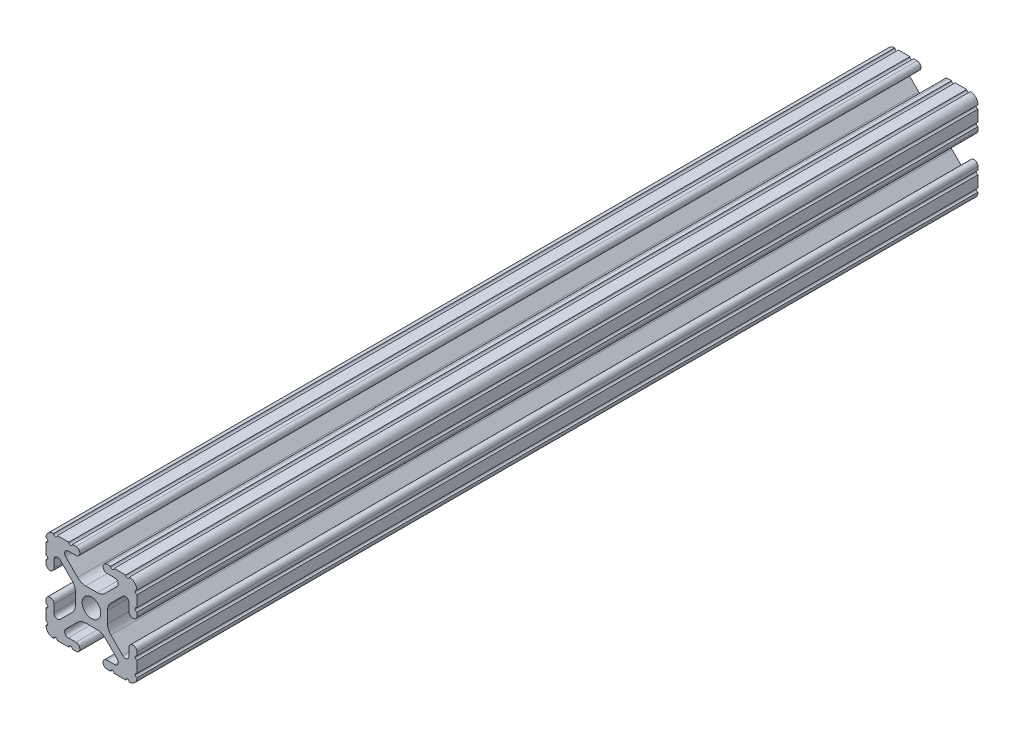
from build123d import *

# Parameters (mm, degrees)
SKETCH1_R           = 2.6035
BOSS_EXTRUDE1_DEPTH = 117.5004


with BuildPart() as part:
    # Sketch1 → Boss-Extrude1 (new body, symmetric)
    with BuildSketch(Plane(origin=(0, 0, -450.85), x_dir=(-1, 0, 0), z_dir=(0, 0, -1))):
        with BuildLine():
            Line((12.7, -9.5504), (12.7, -6.3330836))
            ThreePointArc((12.7, -6.3330836), (12.192, -5.8250836), (12.7, -5.3170836))
            Line((12.7, -5.3170836), (12.7, -4.3434))
            ThreePointArc((12.7, -4.3434), (11.5951, -3.2385), (10.4902, -4.3434))
            Line((10.4902, -4.3434), (10.4902, -6.474794456))
            ThreePointArc((10.4902, -6.474794456), (9.863006367, -7.413456061), (8.75577951, -7.193214945))
            Line((8.75577951, -7.193214945), (5.42573597, -3.863171405))
            ThreePointArc((5.42573597, -3.863171405), (4.737482484, -2.833127272), (4.4958, -1.618107374))
            Line((4.4958, -1.618107374), (4.4958, 1.618107374))
            ThreePointArc((4.4958, 1.618107374), (4.737482484, 2.833127272), (5.42573597, 3.863171405))
            Line((5.42573597, 3.863171405), (8.75577951, 7.193214945))
            ThreePointArc((8.75577951, 7.193214945), (9.863006367, 7.413456061), (10.4902, 6.474794456))
            Line((10.4902, 6.474794456), (10.4902, 4.343399971))
            ThreePointArc((10.4902, 4.343399971), (11.5951, 3.238499971), (12.7, 4.343399971))
            Line((12.7, 4.343399971), (12.7, 5.3170836))
            ThreePointArc((12.7, 5.3170836), (12.192, 5.8250836), (12.7, 6.3330836))
            Line((12.7, 6.3330836), (12.7, 9.5504))
            ThreePointArc((12.7, 9.5504), (12.192000006, 10.058323491), (12.699846982, 10.566399977))
            ThreePointArc((12.699846982, 10.566399977), (12.082522516, 12.082522516), (10.566399977, 12.699846982))
            ThreePointArc((10.566399977, 12.699846982), (10.058323491, 12.192000006), (9.5504, 12.7))
            Line((9.5504, 12.7), (6.3330836, 12.7))
            ThreePointArc((6.3330836, 12.7), (5.8250836, 12.192), (5.3170836, 12.7))
            Line((5.3170836, 12.7), (4.3434, 12.7))
            ThreePointArc((4.3434, 12.7), (3.2385, 11.5951), (4.3434, 10.4902))
            Line((4.3434, 10.4902), (6.474794456, 10.4902))
            ThreePointArc((6.474794456, 10.4902), (7.413456061, 9.863006367), (7.193214945, 8.75577951))
            Line((7.193214945, 8.75577951), (3.863171405, 5.42573597))
            ThreePointArc((3.863171405, 5.42573597), (2.833127272, 4.737482484), (1.618107374, 4.4958))
            Line((1.618107374, 4.4958), (-1.618107374, 4.4958))
            ThreePointArc((-1.618107374, 4.4958), (-2.833127272, 4.737482484), (-3.863171405, 5.42573597))
            Line((-3.863171405, 5.42573597), (-7.193214945, 8.75577951))
            ThreePointArc((-7.193214945, 8.75577951), (-7.413456061, 9.863006367), (-6.474794456, 10.4902))
            Line((-6.474794456, 10.4902), (-4.343399971, 10.4902))
            ThreePointArc((-4.343399971, 10.4902), (-3.238499971, 11.5951), (-4.343399971, 12.7))
            Line((-4.343399971, 12.7), (-5.3170836, 12.7))
            ThreePointArc((-5.3170836, 12.7), (-5.8250836, 12.192), (-6.3330836, 12.7))
            Line((-6.3330836, 12.7), (-9.5504, 12.7))
            ThreePointArc((-9.5504, 12.7), (-10.058323491, 12.192000006), (-10.566399977, 12.699846982))
            ThreePointArc((-10.566399977, 12.699846982), (-12.082522516, 12.082522516), (-12.699846982, 10.566399977))
            ThreePointArc((-12.699846982, 10.566399977), (-12.192000006, 10.058323491), (-12.7, 9.5504))
            Line((-12.7, 9.5504), (-12.7, 6.3330836))
            ThreePointArc((-12.7, 6.3330836), (-12.192, 5.8250836), (-12.7, 5.3170836))
            Line((-12.7, 5.3170836), (-12.7, 4.3434))
            ThreePointArc((-12.7, 4.3434), (-11.5951, 3.2385), (-10.4902, 4.3434))
            Line((-10.4902, 4.3434), (-10.4902, 6.474794456))
            ThreePointArc((-10.4902, 6.474794456), (-9.863006367, 7.413456061), (-8.75577951, 7.193214945))
            Line((-8.75577951, 7.193214945), (-5.42573597, 3.863171405))
            ThreePointArc((-5.42573597, 3.863171405), (-4.737482484, 2.833127272), (-4.4958, 1.618107374))
            Line((-4.4958, 1.618107374), (-4.4958, -1.618107374))
            ThreePointArc((-4.4958, -1.618107374), (-4.737482484, -2.833127272), (-5.42573597, -3.863171405))
            Line((-5.42573597, -3.863171405), (-8.75577951, -7.193214945))
            ThreePointArc((-8.75577951, -7.193214945), (-9.863006367, -7.413456061), (-10.4902, -6.474794456))
            Line((-10.4902, -6.474794456), (-10.4902, -4.343399971))
            ThreePointArc((-10.4902, -4.343399971), (-11.5951, -3.238499971), (-12.7, -4.343399971))
            Line((-12.7, -4.343399971), (-12.7, -5.3170836))
            ThreePointArc((-12.7, -5.3170836), (-12.192, -5.8250836), (-12.7, -6.3330836))
            Line((-12.7, -6.3330836), (-12.7, -9.5504))
            ThreePointArc((-12.7, -9.5504), (-12.192000006, -10.058323491), (-12.699846982, -10.566399977))
            ThreePointArc((-12.699846982, -10.566399977), (-12.082522516, -12.082522516), (-10.566399977, -12.699846982))
            ThreePointArc((-10.566399977, -12.699846982), (-10.058323491, -12.192000006), (-9.5504, -12.7))
            Line((-9.5504, -12.7), (-6.3330836, -12.7))
            ThreePointArc((-6.3330836, -12.7), (-5.8250836, -12.192), (-5.3170836, -12.7))
            Line((-5.3170836, -12.7), (-4.3434, -12.7))
            ThreePointArc((-4.3434, -12.7), (-3.2385, -11.5951), (-4.3434, -10.4902))
            Line((-4.3434, -10.4902), (-6.474794456, -10.4902))
            ThreePointArc((-6.474794456, -10.4902), (-7.413456061, -9.863006367), (-7.193214945, -8.75577951))
            Line((-7.193214945, -8.75577951), (-3.863171405, -5.42573597))
            ThreePointArc((-3.863171405, -5.42573597), (-2.833127272, -4.737482484), (-1.618107374, -4.4958))
            Line((-1.618107374, -4.4958), (1.618107374, -4.4958))
            ThreePointArc((1.618107374, -4.4958), (2.833127272, -4.737482484), (3.863171405, -5.42573597))
            Line((3.863171405, -5.42573597), (7.193214945, -8.75577951))
            ThreePointArc((7.193214945, -8.75577951), (7.413456061, -9.863006367), (6.474794456, -10.4902))
            Line((6.474794456, -10.4902), (4.343399971, -10.4902))
            ThreePointArc((4.343399971, -10.4902), (3.238499971, -11.5951), (4.343399971, -12.7))
            Line((4.343399971, -12.7), (5.3170836, -12.7))
            ThreePointArc((5.3170836, -12.7), (5.8250836, -12.192), (6.3330836, -12.7))
            Line((6.3330836, -12.7), (9.5504, -12.7))
            ThreePointArc((9.5504, -12.7), (10.058323491, -12.192000006), (10.566399977, -12.699846982))
            ThreePointArc((10.566399977, -12.699846982), (12.082522516, -12.082522516), (12.699846982, -10.566399977))
            ThreePointArc((12.699846982, -10.566399977), (12.192000006, -10.058323491), (12.7, -9.5504))
        make_face()
        Circle(SKETCH1_R, mode=Mode.SUBTRACT)
    extrude(amount=BOSS_EXTRUDE1_DEPTH, both=True)


solid = part.part
